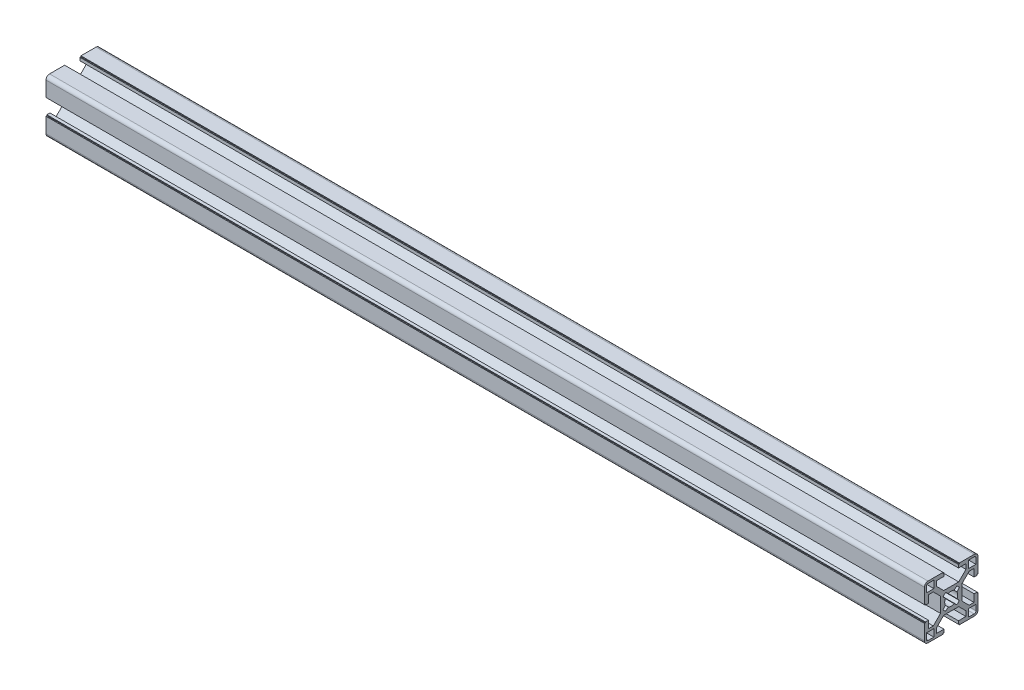
from build123d import *

# Parameters (mm, degrees)
BR_EXTRUDE_DEPTH      = 255
BR_EXTRUDE_DEPTH_BACK = 237


with BuildPart() as part:
    # Sketch2 → BR_Extrude (new body, two sides)
    with BuildSketch(Plane(origin=(0, 0, 0), x_dir=(0, 0, -1), z_dir=(1, 0, 0))) as br_extrude_sk:
        with BuildLine():
            Line((-6, 4.196877708), (-10.053122292, 8.25))
            Line((-10.053122292, 8.25), (-12.8, 8.25))
            Line((-12.8, 8.25), (-12.800036742, 4.05))
            Line((-12.800036742, 4.05), (-14.5, 4.05))
            Line((-14.5, 4.05), (-14.5, 4.55))
            Line((-14.5, 4.55), (-15, 4.55))
            Line((-15, 4.55), (-15, 13))
            ThreePointArc((-15, 13), (-14.414213562, 14.414213562), (-13, 15))
            Line((-13, 15), (-4.55, 15))
            Line((-4.55, 15), (-4.55, 14.5))
            Line((-4.55, 14.5), (-4.05, 14.5))
            Line((-4.05, 14.5), (-4.05, 12.800036742))
            Line((-4.05, 12.800036742), (-8.25, 12.8))
            Line((-8.25, 12.8), (-8.25, 10.053122292))
            Line((-8.25, 10.053122292), (-4.196877708, 6))
            Line((-4.196877708, 6), (4.196877708, 6))
            Line((4.196877708, 6), (8.25, 10.053122292))
            Line((8.25, 10.053122292), (8.25, 12.8))
            Line((8.25, 12.8), (4.05, 12.800036742))
            Line((4.05, 12.800036742), (4.05, 14.5))
            Line((4.05, 14.5), (4.55, 14.5))
            Line((4.55, 14.5), (4.55, 15))
            Line((4.55, 15), (13, 15))
            ThreePointArc((13, 15), (14.414213562, 14.414213562), (15, 13))
            Line((15, 13), (15, 4.55))
            Line((15, 4.55), (14.5, 4.55))
            Line((14.5, 4.55), (14.5, 4.05))
            Line((14.5, 4.05), (12.800036742, 4.05))
            Line((12.800036742, 4.05), (12.8, 8.25))
            Line((12.8, 8.25), (10.053122292, 8.25))
            Line((10.053122292, 8.25), (6, 4.196877708))
            Line((6, 4.196877708), (6, -4.196877708))
            Line((6, -4.196877708), (10.053122292, -8.25))
            Line((10.053122292, -8.25), (12.8, -8.25))
            Line((12.8, -8.25), (12.800036742, -4.05))
            Line((12.800036742, -4.05), (14.5, -4.05))
            Line((14.5, -4.05), (14.5, -4.55))
            Line((14.5, -4.55), (15, -4.55))
            Line((15, -4.55), (15, -13))
            ThreePointArc((15, -13), (14.414213562, -14.414213562), (13, -15))
            Line((13, -15), (4.55, -15))
            Line((4.55, -15), (4.55, -14.5))
            Line((4.55, -14.5), (4.05, -14.5))
            Line((4.05, -14.5), (4.05, -12.800036742))
            Line((4.05, -12.800036742), (8.25, -12.8))
            Line((8.25, -12.8), (8.25, -10.053122292))
            Line((8.25, -10.053122292), (4.196877708, -6))
            Line((4.196877708, -6), (-4.196877708, -6))
            Line((-4.196877708, -6), (-8.25, -10.053122292))
            Line((-8.25, -10.053122292), (-8.25, -12.8))
            Line((-8.25, -12.8), (-4.05, -12.800036742))
            Line((-4.05, -12.800036742), (-4.05, -14.5))
            Line((-4.05, -14.5), (-4.55, -14.5))
            Line((-4.55, -14.5), (-4.55, -15))
            Line((-4.55, -15), (-13, -15))
            ThreePointArc((-13, -15), (-14.414213562, -14.414213562), (-15, -13))
            Line((-15, -13), (-15, -4.55))
            Line((-15, -4.55), (-14.5, -4.55))
            Line((-14.5, -4.55), (-14.5, -4.05))
            Line((-14.5, -4.05), (-12.800036742, -4.05))
            Line((-12.800036742, -4.05), (-12.8, -8.25))
            Line((-12.8, -8.25), (-10.053122292, -8.25))
            Line((-10.053122292, -8.25), (-6, -4.196877708))
            Line((-6, -4.196877708), (-6, 4.196877708))
        make_face()
        with BuildLine():
            Line((-13.85, -9.7), (-13.85, -12.85))
            ThreePointArc((-13.85, -12.85), (-13.557106781, -13.557106781), (-12.85, -13.85))
            Line((-12.85, -13.85), (-9.7, -13.85))
            Line((-9.7, -13.85), (-9.7, -9.7))
            Line((-9.7, -9.7), (-13.85, -9.7))
        make_face(mode=Mode.SUBTRACT)
        with BuildLine():
            Line((9.7, -13.85), (12.85, -13.85))
            ThreePointArc((12.85, -13.85), (13.557106781, -13.557106781), (13.85, -12.85))
            Line((13.85, -12.85), (13.85, -9.7))
            Line((13.85, -9.7), (9.7, -9.7))
            Line((9.7, -9.7), (9.7, -13.85))
        make_face(mode=Mode.SUBTRACT)
        with BuildLine():
            Line((13.85, 9.7), (13.85, 12.85))
            ThreePointArc((13.85, 12.85), (13.557106781, 13.557106781), (12.85, 13.85))
            Line((12.85, 13.85), (9.7, 13.85))
            Line((9.7, 13.85), (9.7, 9.7))
            Line((9.7, 9.7), (13.85, 9.7))
        make_face(mode=Mode.SUBTRACT)
        with BuildLine():
            Line((-9.7, 13.85), (-12.85, 13.85))
            ThreePointArc((-12.85, 13.85), (-13.557106781, 13.557106781), (-13.85, 12.85))
            Line((-13.85, 12.85), (-13.85, 9.7))
            Line((-13.85, 9.7), (-9.7, 9.7))
            Line((-9.7, 9.7), (-9.7, 13.85))
        make_face(mode=Mode.SUBTRACT)
        with BuildLine():
            Line((-3.272394192, -1.616767223), (-4.59052283, -3.187651763))
            Line((-4.59052283, -3.187651763), (-3.187651763, -4.59052283))
            Line((-3.187651763, -4.59052283), (-1.616767223, -3.272394192))
            ThreePointArc((-1.616767223, -3.272394192), (0, -3.65), (1.616767223, -3.272394192))
            Line((1.616767223, -3.272394192), (3.187651763, -4.59052283))
            Line((3.187651763, -4.59052283), (4.59052283, -3.187651763))
            Line((4.59052283, -3.187651763), (3.272394192, -1.616767223))
            ThreePointArc((3.272394192, -1.616767223), (3.65, 0), (3.272394192, 1.616767223))
            Line((3.272394192, 1.616767223), (4.59052283, 3.187651763))
            Line((4.59052283, 3.187651763), (3.187651763, 4.59052283))
            Line((3.187651763, 4.59052283), (1.616767223, 3.272394192))
            ThreePointArc((1.616767223, 3.272394192), (0, 3.65), (-1.616767223, 3.272394192))
            Line((-1.616767223, 3.272394192), (-3.187651763, 4.59052283))
            Line((-3.187651763, 4.59052283), (-4.59052283, 3.187651763))
            Line((-4.59052283, 3.187651763), (-3.272394192, 1.616767223))
            ThreePointArc((-3.272394192, 1.616767223), (-3.65, 0), (-3.272394192, -1.616767223))
        make_face(mode=Mode.SUBTRACT)
    extrude(amount=BR_EXTRUDE_DEPTH)
    extrude(br_extrude_sk.sketch, amount=-BR_EXTRUDE_DEPTH_BACK)


solid = part.part
